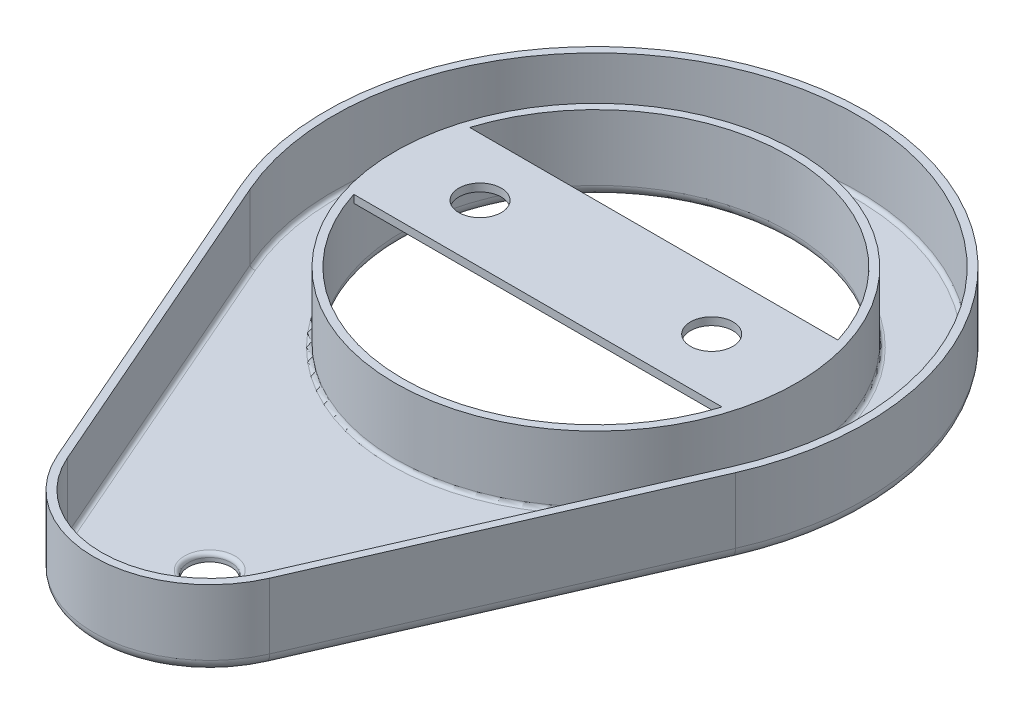
from build123d import *

# Parameters (mm, degrees)
SKETCH1_R           = 25
BOSS_EXTRUDE1_DEPTH = 10
SHELL1_T            = -1
BOSS_EXTRUDE2_DEPTH = 1
CUT_EXTRUDE1_REACH  = 94.363
SKETCH4_R           = 2.75
FILLET1_R           = 0.5
FILLET2_R           = 1.5
CUT_EXTRUDE2_REACH  = 94.363
SKETCH5_R           = 2.75


with BuildPart() as part:
    # Sketch1 → Boss-Extrude1 (new body)
    with BuildSketch(Plane(origin=(0, 0, 0), x_dir=(1, 0, 0), z_dir=(0, 1, 0))):
        with BuildLine():
            Line((13.747727085, -6), (32.078029865, 36))
            ThreePointArc((32.078029865, 36), (0, 85), (-32.078029865, 36))
            Line((-32.078029865, 36), (-13.747727085, -6))
            ThreePointArc((-13.747727085, -6), (0, -15), (13.747727085, -6))
        make_face()
        with Locations(Location((0, 50, 0), (0, 0, 270))):
            Circle(SKETCH1_R, mode=Mode.SUBTRACT)
    extrude(amount=BOSS_EXTRUDE1_DEPTH)

    # Shell1
    shell1_openings = [part.faces().sort_by_distance(p)[0] for p in [
        (-21.794129173, 10, -15.488262225),
    ]]
    offset(amount=SHELL1_T, openings=shell1_openings, kind=Kind.INTERSECTION)

    # Sketch3 → Boss-Extrude2 (add)
    with BuildSketch(Plane(origin=(0, 10, 0), x_dir=(1, 0, 0), z_dir=(0, 1, 0))):
        with BuildLine():
            Line((-23.848480035, 57.5), (23.848480035, 57.5))
            ThreePointArc((23.848480035, 57.5), (25, 50), (23.848480035, 42.5))
            Line((23.848480035, 42.5), (-23.848480035, 42.5))
            ThreePointArc((-23.848480035, 42.5), (-25, 50), (-23.848480035, 57.5))
        make_face()
    extrude(amount=-BOSS_EXTRUDE2_DEPTH)

    # Sketch4 → Cut-Extrude1 (cut, up to next)
    with BuildSketch(Plane(origin=(0, 1, 0), x_dir=(1, 0, 0), z_dir=(0, 1, 0)), mode=Mode.PRIVATE) as cut_extrude1_sk1:
        with Locations(Location((0, 0, 0), (0, 0, 270))):
            Circle(SKETCH4_R)
    cut_extrude1_tool1 = extrude(cut_extrude1_sk1.sketch, amount=-CUT_EXTRUDE1_REACH, mode=Mode.PRIVATE) & part.part
    add(cut_extrude1_tool1.solids().sort_by_distance((0, 1, 0))[0], mode=Mode.SUBTRACT)

    # Fillet1
    fillet1_edges = [part.edges().sort_by_distance(p)[0] for p in [
        (0, 1, -76),
        (0, 1, 14),
        (21.996363336, 1, -15.4),
        (0, 1, -84),
        (-21.996363336, 1, -15.4),
        (0, 1, -2.75),
    ]]
    fillet(fillet1_edges, radius=FILLET1_R)

    # Fillet2
    fillet2_edges = [part.edges().sort_by_distance(p)[0] for p in [
        (0, 0, -75),
        (-22.912878475, 0, -15),
        (0, 0, -85),
        (22.912878475, 0, -15),
        (0, 0, 15),
    ]]
    fillet(fillet2_edges, radius=FILLET2_R)

    # Sketch5 → Cut-Extrude2 (cut, up to next)
    with BuildSketch(Plane.XZ.offset(-9), mode=Mode.PRIVATE) as cut_extrude2_sk1:
        with Locations(Location((15, -50, 0), (0, 0, 270))):
            Circle(SKETCH5_R)
    cut_extrude2_tool1 = extrude(cut_extrude2_sk1.sketch, amount=-CUT_EXTRUDE2_REACH, mode=Mode.PRIVATE) & part.part
    # Sketch5 → Cut-Extrude2 (cut, up to next)
    with BuildSketch(Plane.XZ.offset(-9), mode=Mode.PRIVATE) as cut_extrude2_sk2:
        with Locations(Location((-15, -50, 0), (0, 0, 90))):
            Circle(SKETCH5_R)
    cut_extrude2_tool2 = extrude(cut_extrude2_sk2.sketch, amount=-CUT_EXTRUDE2_REACH, mode=Mode.PRIVATE) & part.part
    add(cut_extrude2_tool1.solids().sort_by_distance((15, 9, -50))[0], mode=Mode.SUBTRACT)
    add(cut_extrude2_tool2.solids().sort_by_distance((-15, 9, -50))[0], mode=Mode.SUBTRACT)


solid = part.part
